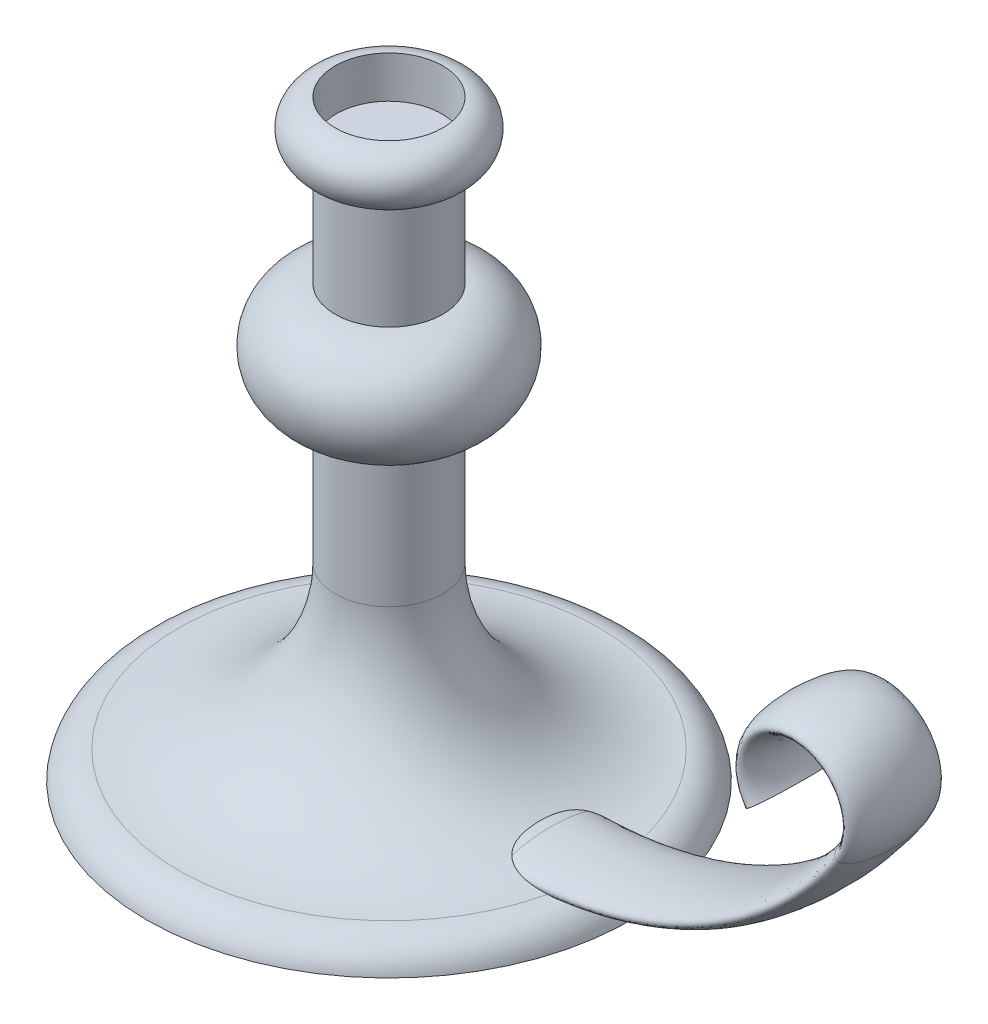
from build123d import *

# Parameters (mm, degrees)
SKETCH5_RX         = 444.5
SKETCH5_RY         = 127
SKETCH7_R          = 508
CUT_EXTRUDE1_DEPTH = 387.604
CUT_EXTRUDE1_TAPER = 1.5


with BuildPart() as part:
    # Sketch1 → Revolve1 (revolve)
    with BuildSketch(Plane.XY):
        with BuildLine():
            Line((0, 0), (0, 5588))
            Line((0, 5588), (508, 5588))
            ThreePointArc((508, 5588), (762, 5334), (508, 5080))
            Line((508, 5080), (508, 4064))
            ThreePointArc((508, 4064), (1016, 3556), (508, 3048))
            Line((508, 3048), (508, 1778))
            ThreePointArc((508, 1778), (937.741842902, 717.257295276), (1984.607723917, 254.737064008))
            ThreePointArc((1984.607723917, 254.737064008), (2179.686319037, 179.879656796), (2286, 0))
            Line((2286, 0), (0, 0))
        make_face()
    revolve(axis=Axis((0, 0, 0), (0, 1, 0)))

    # Sweep1: sweep along a path in Sketch2
    with BuildLine(Plane.XY) as sweep1_path:
        Line((0, 254), (1524, 254))
        ThreePointArc((1524, 254), (3297.458485559, 691.916815973), (4663.238601954, 1905))
        ThreePointArc((4663.238601954, 1905), (4244.673455027, 2700.866666667), (3826.1083081, 1905))
    # Sketch5 → Sweep1 (sweep)
    with BuildSketch(Plane(origin=(0, 0, 0), x_dir=(0, 0, -1), z_dir=(1, 0, 0))):
        with Locations((0, 254)):
            Ellipse(SKETCH5_RX, SKETCH5_RY)
    sweep(path=sweep1_path.line)

    # Sketch7 → Cut-Extrude1 (cut)
    with BuildSketch(Plane(origin=(0, 5588, 0), x_dir=(1, 0, 0), z_dir=(0, 1, 0))):
        Circle(SKETCH7_R)
    extrude(amount=-CUT_EXTRUDE1_DEPTH, taper=CUT_EXTRUDE1_TAPER, mode=Mode.SUBTRACT)


solid = part.part
